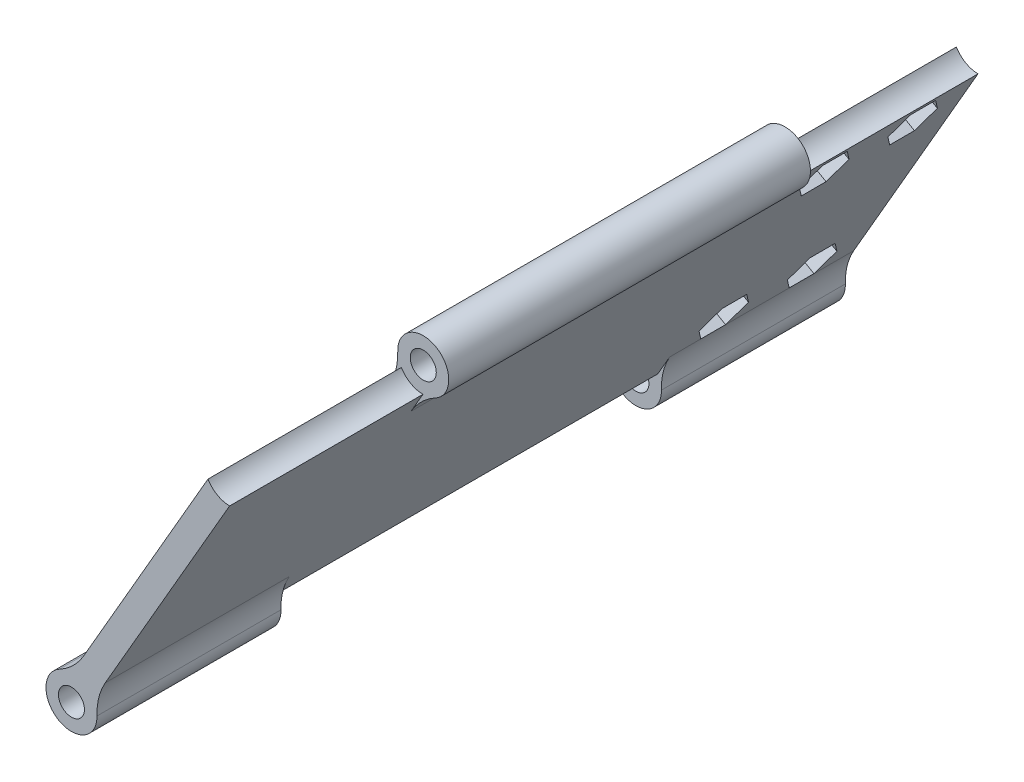
from build123d import *

# Parameters (mm, degrees)
SKETCH2_R               = 1.5875
BOSS_EXTRUDE1_DEPTH     = 10
BOSS_EXTRUDE2_DEPTH     = 120
SKETCH4_R               = 4.0875
CUT_EXTRUDE1_DEPTH      = 30.5
CUT_EXTRUDE1_DEPTH_BACK = 30.5
SKETCH5_R               = 4.0875
CUT_EXTRUDE2_DEPTH      = 31
SKETCH6_R               = 4.0875
CUT_EXTRUDE3_DEPTH      = 31
FILLET1_R               = 10
SKETCH7_R               = 1.5
CUT_EXTRUDE4_DEPTH      = 4
SKETCH8_R               = 1.5
CUT_EXTRUDE5_DEPTH      = 2


with BuildPart() as part:
    # Sketch2 → Boss-Extrude1 (new body)
    with BuildSketch(Plane.XY):
        with BuildLine():
            Line((0, -27.7495), (0, 0))
            Line((0, 0), (38.1, 0))
            ThreePointArc((38.1, 0), (-26.940768363, 26.940768363), (0, -38.1))
            Line((0, -38.1), (0, -30.9245))
            ThreePointArc((0, -30.9245), (-1.5875, -29.337), (0, -27.7495))
        make_face()
        with Locations((-25.406587271, 14.6685)):
            Circle(SKETCH2_R, mode=Mode.SUBTRACT)
        with Locations((25.406587271, 14.6685)):
            Circle(SKETCH2_R, mode=Mode.SUBTRACT)
        with BuildLine():
            Line((38.1, 0), (0, 0))
            Line((0, 0), (0, -27.7495))
            ThreePointArc((0, -27.7495), (1.122532015, -28.214467985), (1.5875, -29.337))
            ThreePointArc((1.5875, -29.337), (1.122532015, -30.459532015), (0, -30.9245))
            Line((0, -30.9245), (0, -38.1))
            ThreePointArc((0, -38.1), (26.940768363, -26.940768363), (38.1, 0))
        make_face()
    extrude(amount=BOSS_EXTRUDE1_DEPTH)


with BuildPart() as body_2:
    # Sketch3 → Boss-Extrude2 (new body)
    with BuildSketch(Plane.XY.offset(10)):
        with BuildLine():
            ThreePointArc((29.494087271, 14.6685), (24.324372064, 18.610132466), (21.892146477, 12.581309985))
            Line((21.892146477, 12.581309985), (23.37551462, 15.150578976))
            ThreePointArc((23.37551462, 15.150578976), (25.649272347, 16.741845172), (27.494087271, 14.6685))
            ThreePointArc((27.494087271, 14.6685), (27.323499399, 13.841998855), (26.839616236, 13.150578976))
            Line((26.839616236, 13.150578976), (25.356248092, 10.581309985))
            ThreePointArc((25.356248092, 10.581309985), (28.279033516, 11.760457906), (29.494087271, 14.6685))
        make_face()
        with BuildLine():
            Line((24.362837271, 12.86067197), (23.362837271, 11.128621162))
            ThreePointArc((23.362837271, 11.128621162), (24.324372064, 10.726867534), (25.356248092, 10.581309985))
            Line((25.356248092, 10.581309985), (26.839616236, 13.150578976))
            ThreePointArc((26.839616236, 13.150578976), (25.649272347, 12.595154828), (24.362837271, 12.86067197))
        make_face()
        with BuildLine():
            ThreePointArc((21.892146477, 12.581309985), (22.534141026, 11.760457906), (23.362837271, 11.128621162))
            Line((23.362837271, 11.128621162), (24.362837271, 12.86067197))
            ThreePointArc((24.362837271, 12.86067197), (23.489675143, 13.841998855), (23.37551462, 15.150578976))
            Line((23.37551462, 15.150578976), (21.892146477, 12.581309985))
        make_face()
        with BuildLine():
            Line((23.362837271, 11.128621162), (2.04375, -25.797121162))
            ThreePointArc((2.04375, -25.797121162), (2.872446245, -26.428957906), (3.514440794, -27.249809985))
            Line((3.514440794, -27.249809985), (25.356248092, 10.581309985))
            ThreePointArc((25.356248092, 10.581309985), (24.324372064, 10.726867534), (23.362837271, 11.128621162))
        make_face()
        with BuildLine():
            ThreePointArc((0.050339179, -25.249809985), (1.082215206, -25.395367534), (2.04375, -25.797121162))
            Line((2.04375, -25.797121162), (23.362837271, 11.128621162))
            ThreePointArc((23.362837271, 11.128621162), (22.534141026, 11.760457906), (21.892146477, 12.581309985))
            Line((21.892146477, 12.581309985), (0.050339179, -25.249809985))
        make_face()
        with BuildLine():
            ThreePointArc((-1.433028965, -27.819078976), (-0.242685076, -27.263654828), (1.04375, -27.52917197))
            Line((1.04375, -27.52917197), (2.04375, -25.797121162))
            ThreePointArc((2.04375, -25.797121162), (1.082215206, -25.395367534), (0.050339179, -25.249809985))
            Line((0.050339179, -25.249809985), (-1.433028965, -27.819078976))
        make_face()
        with BuildLine():
            Line((2.04375, -25.797121162), (1.04375, -27.52917197))
            ThreePointArc((1.04375, -27.52917197), (1.80782803, -28.29325), (2.0875, -29.337))
            ThreePointArc((2.0875, -29.337), (2.073345172, -29.579685076), (2.03107265, -29.819078976))
            Line((2.03107265, -29.819078976), (3.514440794, -27.249809985))
            ThreePointArc((3.514440794, -27.249809985), (2.872446245, -26.428957906), (2.04375, -25.797121162))
        make_face()
        with BuildLine():
            ThreePointArc((2.03107265, -29.819078976), (-1.04375, -31.14482803), (-1.433028965, -27.819078976))
            Line((-1.433028965, -27.819078976), (0.050339179, -25.249809985))
            ThreePointArc((0.050339179, -25.249809985), (-2.908042094, -32.209446245), (4.0875, -29.337))
            ThreePointArc((4.0875, -29.337), (3.941632466, -28.254784794), (3.514440794, -27.249809985))
            Line((3.514440794, -27.249809985), (2.03107265, -29.819078976))
        make_face()
    extrude(amount=BOSS_EXTRUDE2_DEPTH)

    # Sketch4 → Cut-Extrude1 (cut, two sides)
    with BuildSketch(Plane.XY.offset(70)) as cut_extrude1_sk:
        with Locations((0, -29.337)):
            Circle(SKETCH4_R)
    extrude(amount=CUT_EXTRUDE1_DEPTH, mode=Mode.SUBTRACT)
    extrude(cut_extrude1_sk.sketch, amount=-CUT_EXTRUDE1_DEPTH_BACK, mode=Mode.SUBTRACT)

    # Sketch5 → Cut-Extrude2 (cut)
    with BuildSketch(Plane(origin=(0, 0, 10), x_dir=(-1, 0, 0), z_dir=(0, 0, -1))):
        with Locations((-25.406587271, 14.6685)):
            Circle(SKETCH5_R)
    extrude(amount=-CUT_EXTRUDE2_DEPTH, mode=Mode.SUBTRACT)

    # Sketch6 → Cut-Extrude3 (cut)
    with BuildSketch(Plane.XY.offset(130)):
        with Locations((25.406587271, 14.6685)):
            Circle(SKETCH6_R)
    extrude(amount=-CUT_EXTRUDE3_DEPTH, mode=Mode.SUBTRACT)

    # Fillet1
    fillet1_edges = [body_2.edges().sort_by_distance(p)[0] for p in [
        (0.050339179, -25.249809985, 115.25),
        (3.514440794, -27.249809985, 115.25),
        (0.050339179, -25.249809985, 24.75),
        (3.514440794, -27.249809985, 24.75),
        (21.892146477, 12.581309985, 70),
        (25.356248092, 10.581309985, 70),
    ]]
    fillet(fillet1_edges, radius=FILLET1_R)

    # Sketch7 → Cut-Extrude4 (cut)
    with BuildSketch(Plane(origin=(10.971242828, -6.33425, 0), x_dir=(0, 0, 1), z_dir=(-0.866025404, 0.5, 0))):
        with Locations((18.38424077, -14.582087011)):
            Circle(SKETCH7_R)
        with Locations((18.38424077, 17.647912989)):
            Circle(SKETCH7_R)
        with Locations((32.55424077, 17.647912989)):
            Circle(SKETCH7_R)
        with Locations((32.55424077, -14.582087011)):
            Circle(SKETCH7_R)
    extrude(amount=-CUT_EXTRUDE4_DEPTH, mode=Mode.SUBTRACT)

    # Sketch8 → Cut-Extrude5 (cut)
    with BuildSketch(Plane(origin=(14.435344443, -8.33425, 0), x_dir=(0, 0, -1), z_dir=(0.866025404, -0.5, 0))):
        with Locations((-18.38424077, -14.582087011)):
            Circle(SKETCH8_R)
        Polygon((-34.516051881, 14.208627429), (-30.556637659, 14.22929195), (-28.594826548, 17.66857751), (-30.592429659, 21.08719855), (-34.55184388, 21.066534029), (-36.513654991, 17.627248469), align=None)
        with Locations((-18.38424077, 17.647912989)):
            Circle(SKETCH8_R)
        Polygon((-34.516051881, -18.021372571), (-30.556637659, -18.00070805), (-28.594826548, -14.56142249), (-30.592429659, -11.14280145), (-34.55184388, -11.163465971), (-36.513654991, -14.602751531), align=None)
        with Locations((-32.55424077, 17.647912989)):
            Circle(SKETCH8_R)
        Polygon((-20.346051881, -18.021372571), (-16.386637659, -18.00070805), (-14.424826548, -14.56142249), (-16.422429659, -11.14280145), (-20.38184388, -11.163465971), (-22.343654991, -14.602751531), align=None)
        Polygon((-20.346051881, 14.208627429), (-16.386637659, 14.22929195), (-14.424826548, 17.66857751), (-16.422429659, 21.08719855), (-20.38184388, 21.066534029), (-22.343654991, 17.627248469), align=None)
    extrude(amount=-CUT_EXTRUDE5_DEPTH, mode=Mode.SUBTRACT)


solid = body_2.part
